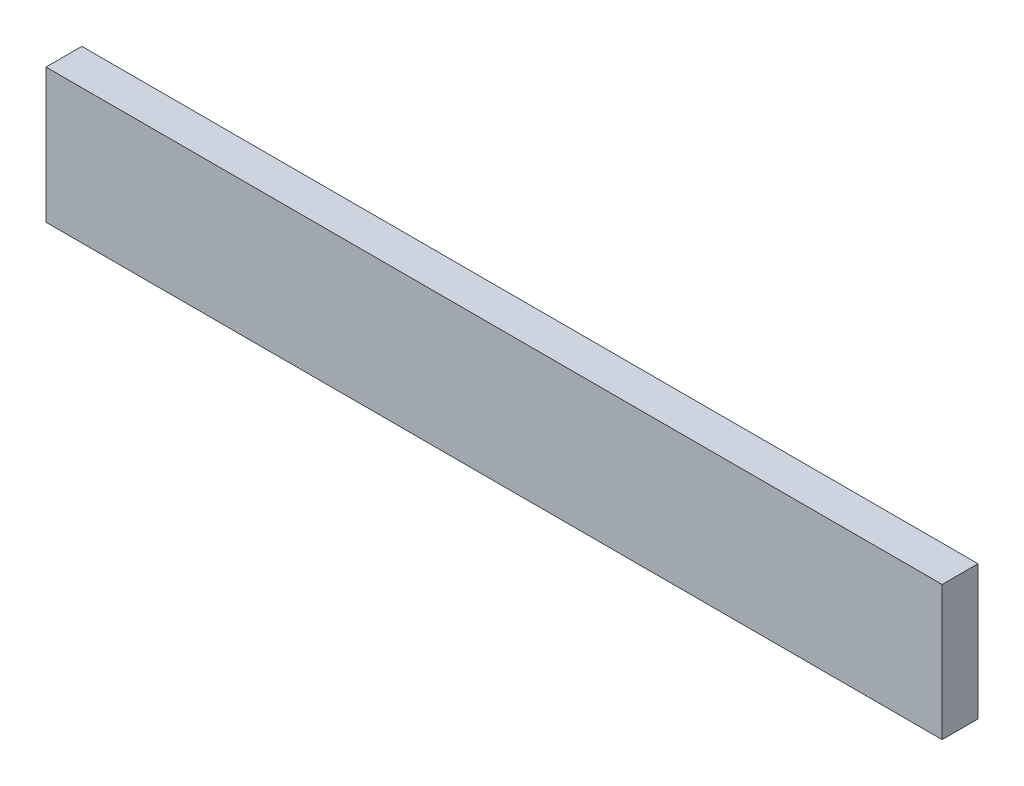
from build123d import *

# Parameters (mm, degrees)
SKETCH1_W           = 127
SKETCH1_H           = 19.05
BOSS_EXTRUDE1_DEPTH = 5.08
SKETCH2_R           = 2.54
BOSS_EXTRUDE2_DEPTH = 10.16


with BuildPart() as part:
    # Sketch1 → Boss-Extrude1 (new body)
    with BuildSketch(Plane.XY):
        with Locations((63.5, 9.525)):
            Rectangle(SKETCH1_W, SKETCH1_H)
    extrude(amount=BOSS_EXTRUDE1_DEPTH)

    # Sketch2 → Boss-Extrude2 (add)
    with BuildSketch(Plane(origin=(0, 0, 0), x_dir=(-1, 0, 0), z_dir=(0, 0, -1))):
        with Locations((-109.22, 3.81)):
            Circle(SKETCH2_R)
        with Locations((-78.74, 3.81)):
            Circle(SKETCH2_R)
        with Locations((-48.26, 3.81)):
            Circle(SKETCH2_R)
        with Locations((-17.78, 3.81)):
            Circle(SKETCH2_R)
    extrude(amount=BOSS_EXTRUDE2_DEPTH)


solid = part.part
